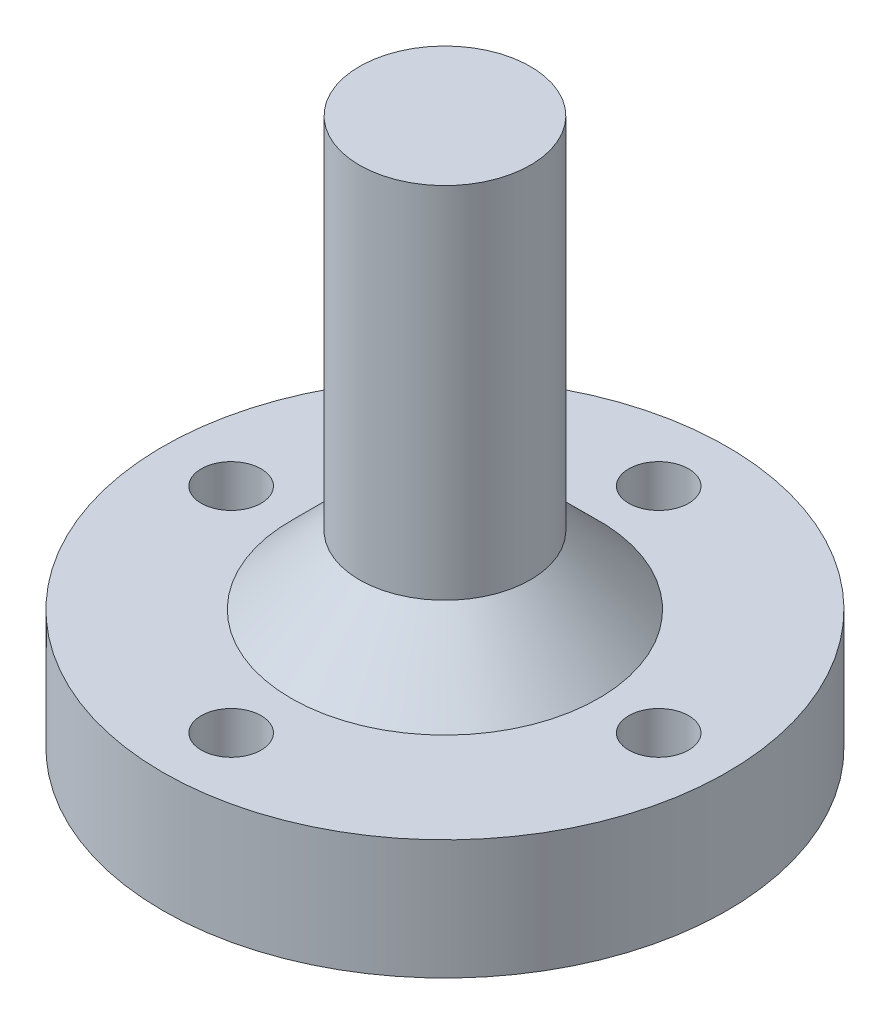
from build123d import *

# Parameters (mm, degrees)
SKETCH1_R           = 16.5
BOSS_EXTRUDE1_DEPTH = 7
SKETCH2_R           = 1.75
CUT_EXTRUDE1_DEPTH  = 8
CIRPATTERN1_COUNT   = 4
SKETCH3_R           = 5
BOSS_EXTRUDE2_DEPTH = 25
CHAMFER1_SIZE       = 4
SKETCH6_R           = 5.25
CUT_EXTRUDE4_DEPTH  = 5.5
SKETCH8_R           = 2.75
CUT_EXTRUDE5_DEPTH  = 6


with BuildPart() as part:
    # Sketch1 → Boss-Extrude1 (new body)
    with BuildSketch(Plane(origin=(0, 0, 0), x_dir=(1, 0, 0), z_dir=(0, 1, 0))):
        Circle(SKETCH1_R)
    extrude(amount=BOSS_EXTRUDE1_DEPTH)

    # Sketch2 → Cut-Extrude1 (cut, through all)
    with BuildSketch(Plane(origin=(0, 7, 0), x_dir=(1, 0, 0), z_dir=(0, 1, 0))):
        with Locations((0, 12.5)):
            Circle(SKETCH2_R)
    cut_extrude1 = extrude(amount=-CUT_EXTRUDE1_DEPTH, mode=Mode.SUBTRACT)

    # CirPattern1: Cut-Extrude1 ×4 about axis
    cirpattern1_axis = Axis((0, 0, 0), (0, 1, 0))
    for i in range(1, CIRPATTERN1_COUNT):
        add(cut_extrude1.rotate(cirpattern1_axis, i * 360 / CIRPATTERN1_COUNT), mode=Mode.SUBTRACT)

    # Sketch3 → Boss-Extrude2 (add)
    with BuildSketch(Plane(origin=(0, 7, 0), x_dir=(1, 0, 0), z_dir=(0, 1, 0))):
        Circle(SKETCH3_R)
    extrude(amount=BOSS_EXTRUDE2_DEPTH)

    # Chamfer1
    chamfer1_edges = [part.edges().sort_by_distance(p)[0] for p in [
        (-5, 7, 0),
    ]]
    chamfer(chamfer1_edges, length=CHAMFER1_SIZE)

    # Sketch6 → Cut-Extrude4 (cut)
    with BuildSketch(Plane.XZ):
        Circle(SKETCH6_R)
    extrude(amount=-CUT_EXTRUDE4_DEPTH, mode=Mode.SUBTRACT)

    # Sketch8 → Cut-Extrude5 (cut)
    with BuildSketch(Plane.XZ.offset(-5.5)):
        Circle(SKETCH8_R)
    extrude(amount=-CUT_EXTRUDE5_DEPTH, mode=Mode.SUBTRACT)


solid = part.part
